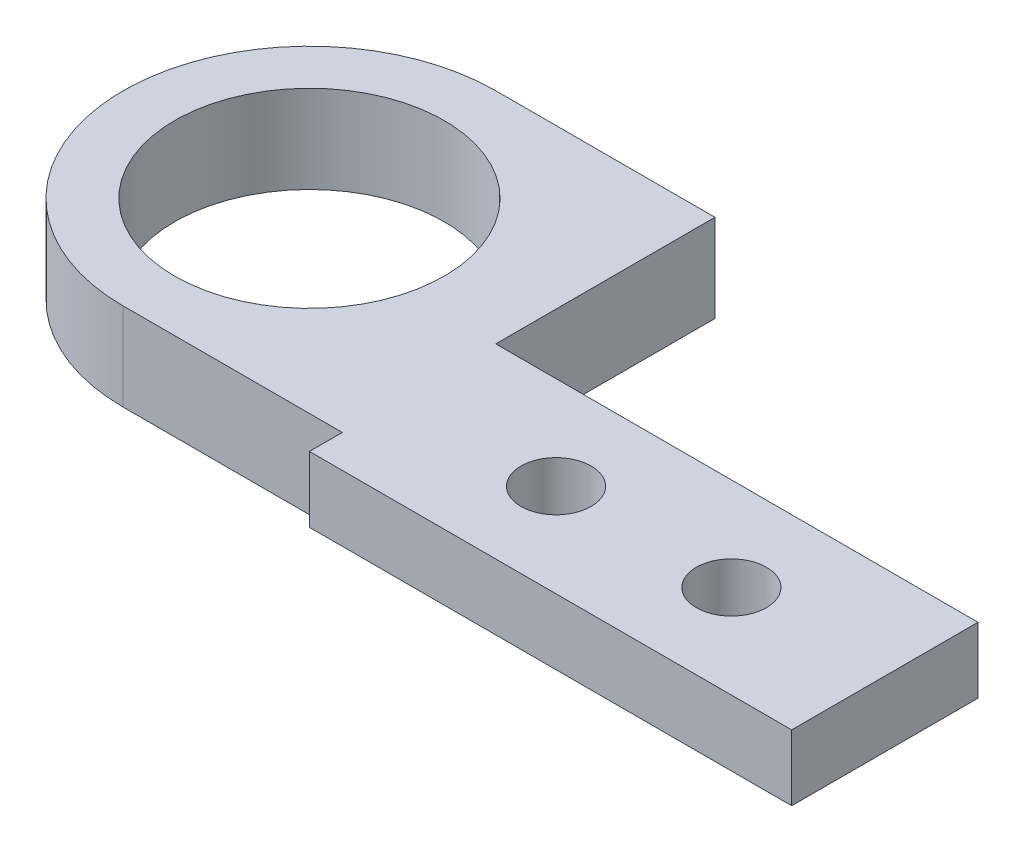
from build123d import *

# Parameters (mm, degrees)
SKETCH1_R           = 6.15
BOSS_EXTRUDE1_DEPTH = 4
BOSS_EXTRUDE3_DEPTH = 3
SKETCH5_R           = 1.6
CUT_EXTRUDE1_DEPTH  = 10


with BuildPart() as part:
    # Sketch1 → Boss-Extrude1 (new body)
    with BuildSketch(Plane(origin=(0, 0, 0), x_dir=(1, 0, 0), z_dir=(0, 1, 0))):
        with BuildLine():
            Line((-7.789088727, -8.5), (2.210911273, -8.5))
            Line((2.210911273, -8.5), (2.210911273, 8.5))
            Line((2.210911273, 8.5), (-7.789088727, 8.5))
            ThreePointArc((-7.789088727, 8.5), (-16.289088727, 0), (-7.789088727, -8.5))
        make_face()
        with Locations((-7.789088727, 0)):
            Circle(SKETCH1_R, mode=Mode.SUBTRACT)
    extrude(amount=BOSS_EXTRUDE1_DEPTH)

    # Sketch4 → Boss-Extrude3 (add)
    with BuildSketch(Plane(origin=(0, 4, 0), x_dir=(1, 0, 0), z_dir=(0, 1, 0))):
        Polygon((24.210911273, -1.5), (2.210911273, -1.5), (2.210911273, -8.5), (2.210911273, -10), (24.210911273, -10), (24.210911273, -8.5), align=None)
    extrude(amount=-BOSS_EXTRUDE3_DEPTH)

    # Sketch5 → Cut-Extrude1 (cut)
    with BuildSketch(Plane(origin=(0, 4, 0), x_dir=(1, 0, 0), z_dir=(0, 1, 0))):
        with Locations((9.210911273, -5.75)):
            Circle(SKETCH5_R)
        with Locations((17.210911273, -5.75)):
            Circle(SKETCH5_R)
    extrude(amount=-CUT_EXTRUDE1_DEPTH, mode=Mode.SUBTRACT)


solid = part.part
